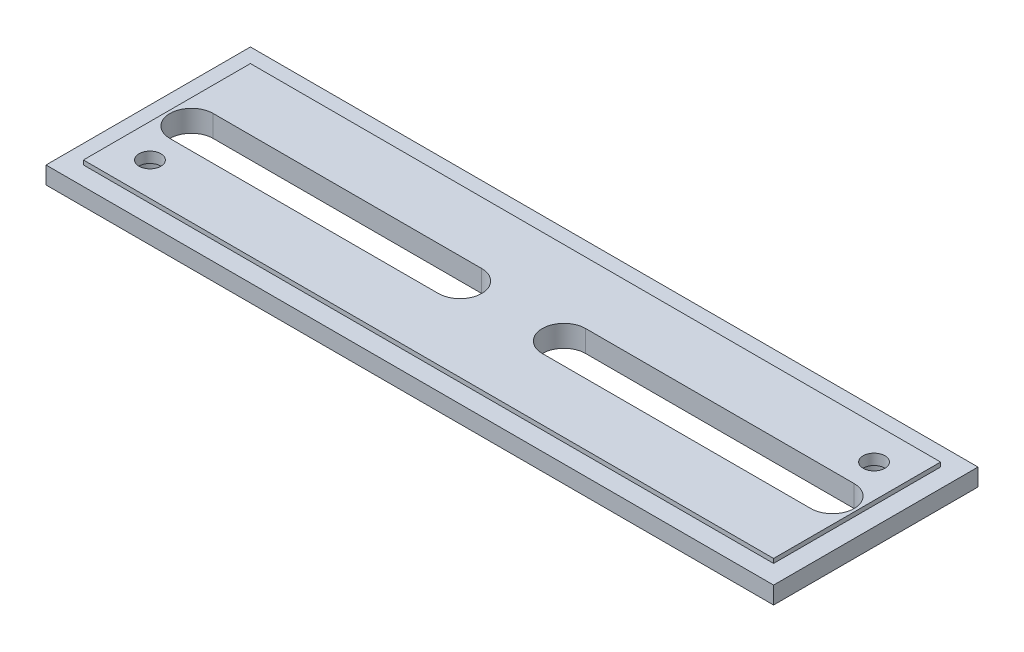
from build123d import *

# Parameters (mm, degrees)
SKETCH1_W           = 133.35
SKETCH1_H           = 37.465
BOSS_EXTRUDE1_DEPTH = 3.175
SKETCH2_W           = 126.492
SKETCH2_H           = 30.607
BOSS_EXTRUDE2_DEPTH = 0.79375
CUT_EXTRUDE1_DEPTH  = 3.96875
CUT_EXTRUDE2_REACH  = 5.969
SKETCH5_R           = 2
SKETCH6_R           = 3.175
CUT_EXTRUDE3_DEPTH  = 2


with BuildPart() as part:
    # Sketch1 → Boss-Extrude1 (new body)
    with BuildSketch(Plane(origin=(0, 0, 0), x_dir=(1, 0, 0), z_dir=(0, 1, 0))):
        Rectangle(SKETCH1_W, SKETCH1_H)
    extrude(amount=BOSS_EXTRUDE1_DEPTH)

    # Sketch2 → Boss-Extrude2 (add)
    with BuildSketch(Plane(origin=(0, 3.175, 0), x_dir=(1, 0, 0), z_dir=(0, 1, 0))):
        Rectangle(SKETCH2_W, SKETCH2_H)
    extrude(amount=BOSS_EXTRUDE2_DEPTH)

    # Sketch3 → Cut-Extrude1 (cut)
    with BuildSketch(Plane(origin=(0, 0, 0), x_dir=(1, 0, 0), z_dir=(0, 1, 0))):
        with BuildLine():
            Line((-9.525, -3.96875), (-58.7375, -3.96875))
            ThreePointArc((-58.7375, -3.96875), (-62.70625, 0), (-58.7375, 3.96875))
            Line((-58.7375, 3.96875), (-9.525, 3.96875))
            ThreePointArc((-9.525, 3.96875), (-5.55625, 0), (-9.525, -3.96875))
        make_face()
    cut_extrude1 = extrude(amount=CUT_EXTRUDE1_DEPTH, mode=Mode.SUBTRACT)

    # Mirror1: Cut-Extrude1 across plane
    add(cut_extrude1.mirror(Plane(origin=(0, 0, 0), x_dir=(0, 0, 1), z_dir=(1, 0, 0))), mode=Mode.SUBTRACT)

    # Sketch5 → Cut-Extrude2 (cut, up to next)
    with BuildSketch(Plane(origin=(0, 0, 0), x_dir=(1, 0, 0), z_dir=(0, 1, 0)), mode=Mode.PRIVATE) as cut_extrude2_sk1:
        with Locations((-57.15, -9.2075)):
            Circle(SKETCH5_R)
    cut_extrude2_tool1 = extrude(cut_extrude2_sk1.sketch, amount=CUT_EXTRUDE2_REACH, mode=Mode.PRIVATE) & part.part
    add(cut_extrude2_tool1.solids().sort_by_distance((-57.15, 0, 9.2075))[0], mode=Mode.SUBTRACT)
    # Sketch5 → Cut-Extrude2 (cut, up to next)
    with BuildSketch(Plane(origin=(0, 0, 0), x_dir=(1, 0, 0), z_dir=(0, 1, 0)), mode=Mode.PRIVATE) as cut_extrude2_sk2:
        with Locations((57.15, 9.2075)):
            Circle(SKETCH5_R)
    cut_extrude2_tool2 = extrude(cut_extrude2_sk2.sketch, amount=CUT_EXTRUDE2_REACH, mode=Mode.PRIVATE) & part.part
    add(cut_extrude2_tool2.solids().sort_by_distance((57.15, 0, -9.2075))[0], mode=Mode.SUBTRACT)

    # Sketch6 → Cut-Extrude3 (cut)
    with BuildSketch(Plane(origin=(0, 0, 0), x_dir=(-1, 0, 0), z_dir=(0, -1, 0))):
        with Locations((57.15, -9.2075)):
            Circle(SKETCH6_R)
        with Locations((-57.15, 9.2075)):
            Circle(SKETCH6_R)
    extrude(amount=-CUT_EXTRUDE3_DEPTH, mode=Mode.SUBTRACT)


solid = part.part
